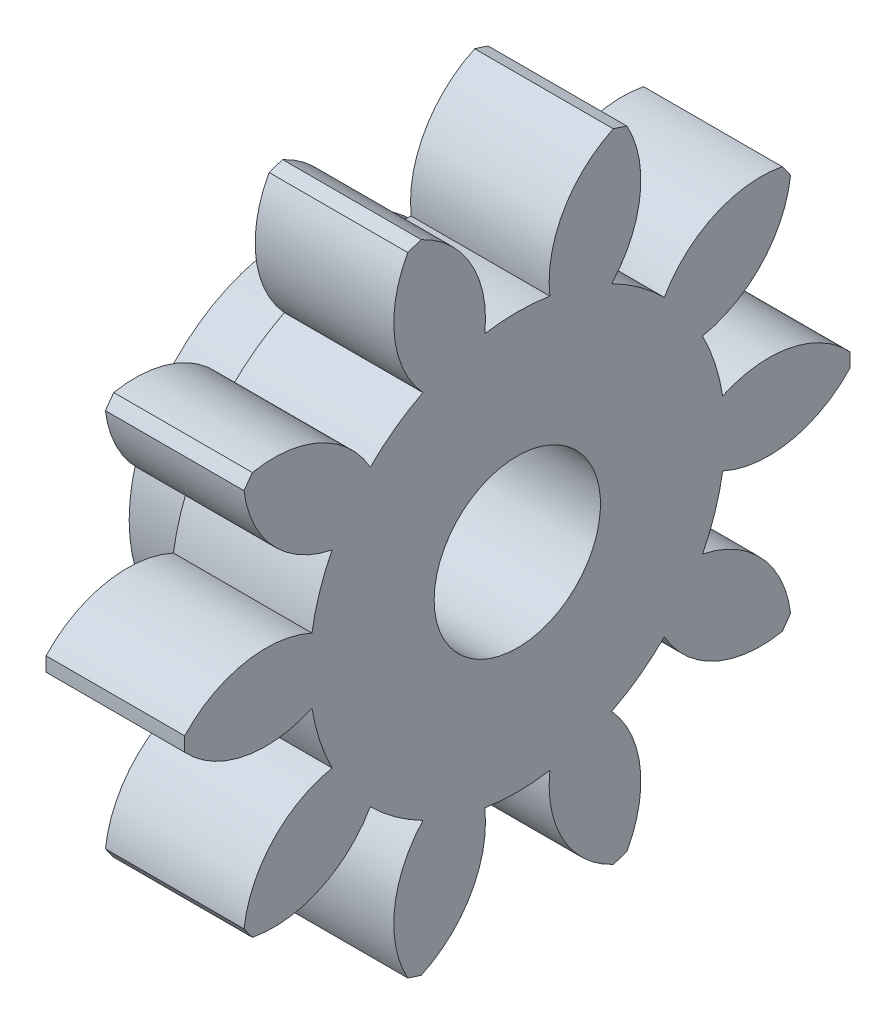
from build123d import *

# Parameters (mm, degrees)
BASPROSKE_W        = 5
BASPROSKE_H        = 12
TOOTHCUT_DEPTH     = 18.691806013
TEETHCUTS_COUNT    = 10
TEETHCUTS_ANGLE    = 324
HUBNEAONESKE_R     = 6
HUBNEARONE_DEPTH   = 3.0000508
BORSKE_R           = 3
BORE_DEPTH         = 8.0000508
SKETCH1_R          = 3.5
SKETCH1_R_2        = 3
CUT_EXTRUDE1_DEPTH = 1


with BuildPart() as part:
    # BasProSke → Base-Revolve (revolve)
    with BuildSketch(Plane(origin=(0, 0, 0), x_dir=(1, 0, 0), z_dir=(0, 1, 0)), mode=Mode.PRIVATE) as base_revolve_sk:
        with Locations((2.5, 6)):
            Rectangle(BASPROSKE_W, BASPROSKE_H)
    revolve(base_revolve_sk.sketch.rotate(Axis((-10, 0, 0), (1, 0, 0)), 180), axis=Axis((-10, 0, 0), (1, 0, 0)))

    # TooCutSke → ToothCut (cut, through all)
    with BuildSketch(Plane(origin=(0, 0, 0), x_dir=(0, 0, -1), z_dir=(1, 0, 0))):
        with BuildLine():
            ThreePointArc((1.173662691, 7.406586048), (0, 7.499), (-1.173662691, 7.406586048))
            ThreePointArc((-1.173662691, 7.406586048), (-1.668191438, 9.834565786), (-3.497907776, 11.50542856))
            ThreePointArc((-3.497907776, 11.50542856), (0, 12.0254), (3.497907776, 11.50542856))
            ThreePointArc((3.497907776, 11.50542856), (1.668191438, 9.834565786), (1.173662691, 7.406586048))
        make_face()
    toothcut = extrude(amount=TOOTHCUT_DEPTH, mode=Mode.SUBTRACT)

    # TeethCuts: ToothCut ×10 about axis
    teethcuts_axis = Axis((-10, 0, 0), (1, 0, 0))
    for i in range(1, TEETHCUTS_COUNT):
        add(toothcut.rotate(teethcuts_axis, i * TEETHCUTS_ANGLE / (TEETHCUTS_COUNT - 1)), mode=Mode.SUBTRACT)

    # HubNeaOneSke → HubNearOne (add)
    with BuildSketch(Plane.ZY):
        with Locations(Location((0, 0, 0), (0, 0, 180))):
            Circle(HUBNEAONESKE_R)
    extrude(amount=HUBNEARONE_DEPTH)

    # BorSke → Bore (cut, symmetric)
    with BuildSketch(Plane(origin=(0, 0, 0), x_dir=(0, 0, -1), z_dir=(1, 0, 0))):
        with Locations(Location((0, 0, 0), (0, 0, 180))):
            Circle(BORSKE_R)
    extrude(amount=BORE_DEPTH, both=True, mode=Mode.SUBTRACT)

    # Sketch1 → Cut-Extrude1 (cut)
    with BuildSketch(Plane.ZY.offset(3.0000508)):
        Circle(SKETCH1_R)
        Circle(SKETCH1_R_2, mode=Mode.SUBTRACT)
    extrude(amount=-CUT_EXTRUDE1_DEPTH, mode=Mode.SUBTRACT)


solid = part.part
